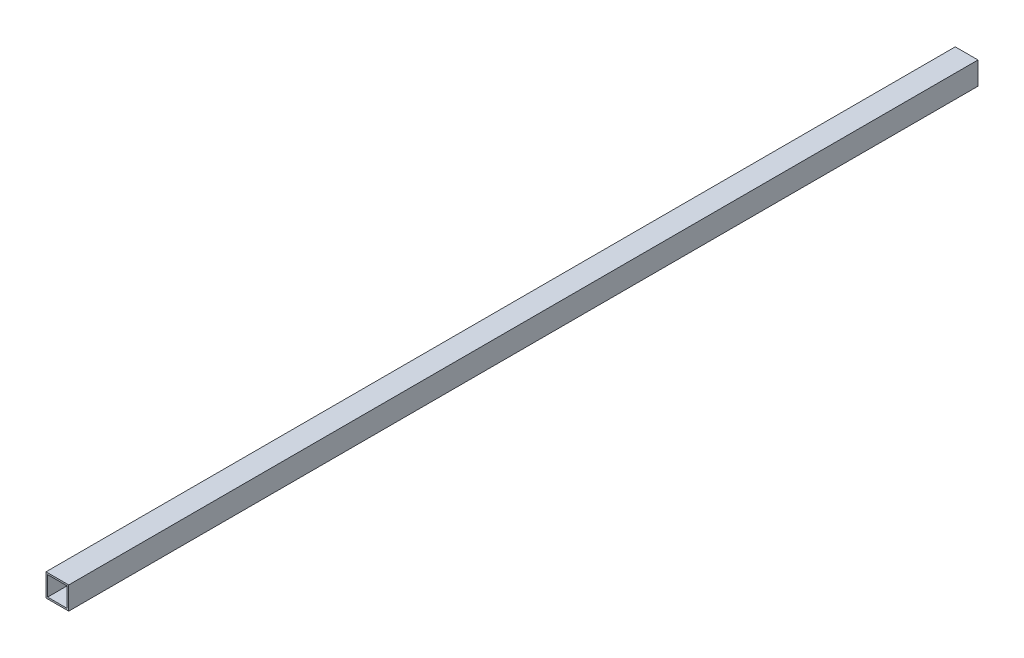
from build123d import *

# Parameters (mm, degrees)
SKETCH1_W           = 44.45
SKETCH1_H           = 44.45
SKETCH1_W_2         = 38.1
SKETCH1_H_2         = 38.1
BOSS_EXTRUDE1_DEPTH = 1778


with BuildPart() as part:
    # Sketch1 → Boss-Extrude1 (new body)
    with BuildSketch(Plane.XY):
        with Locations((22.225, 22.225)):
            Rectangle(SKETCH1_W, SKETCH1_H)
        with Locations((22.225, 22.225)):
            Rectangle(SKETCH1_W_2, SKETCH1_H_2, mode=Mode.SUBTRACT)
    extrude(amount=BOSS_EXTRUDE1_DEPTH)


solid = part.part
